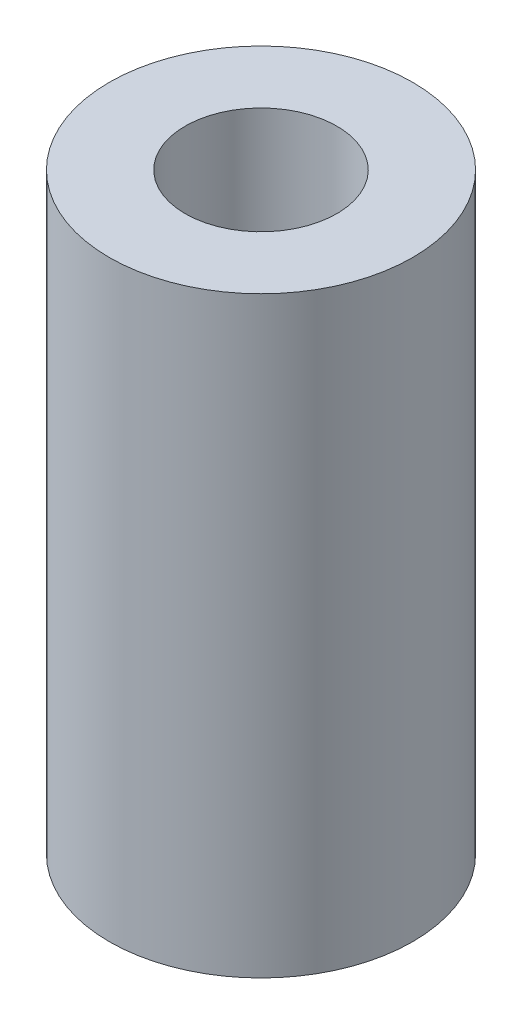
from build123d import *

# Parameters (mm, degrees)
SKETCH1_R           = 6.35
BOSS_EXTRUDE1_DEPTH = 24.79999612
SKETCH2_R           = 3.175
CUT_EXTRUDE1_DEPTH  = 18.6


with BuildPart() as part:
    # Sketch1 → Boss-Extrude1 (new body)
    with BuildSketch(Plane(origin=(0, 0, 0), x_dir=(1, 0, 0), z_dir=(0, 1, 0))):
        Circle(SKETCH1_R)
    extrude(amount=BOSS_EXTRUDE1_DEPTH)

    # Sketch2 → Cut-Extrude1 (cut)
    with BuildSketch(Plane(origin=(0, 24.79999612, 0), x_dir=(1, 0, 0), z_dir=(0, 1, 0))):
        Circle(SKETCH2_R)
    extrude(amount=-CUT_EXTRUDE1_DEPTH, mode=Mode.SUBTRACT)


solid = part.part
